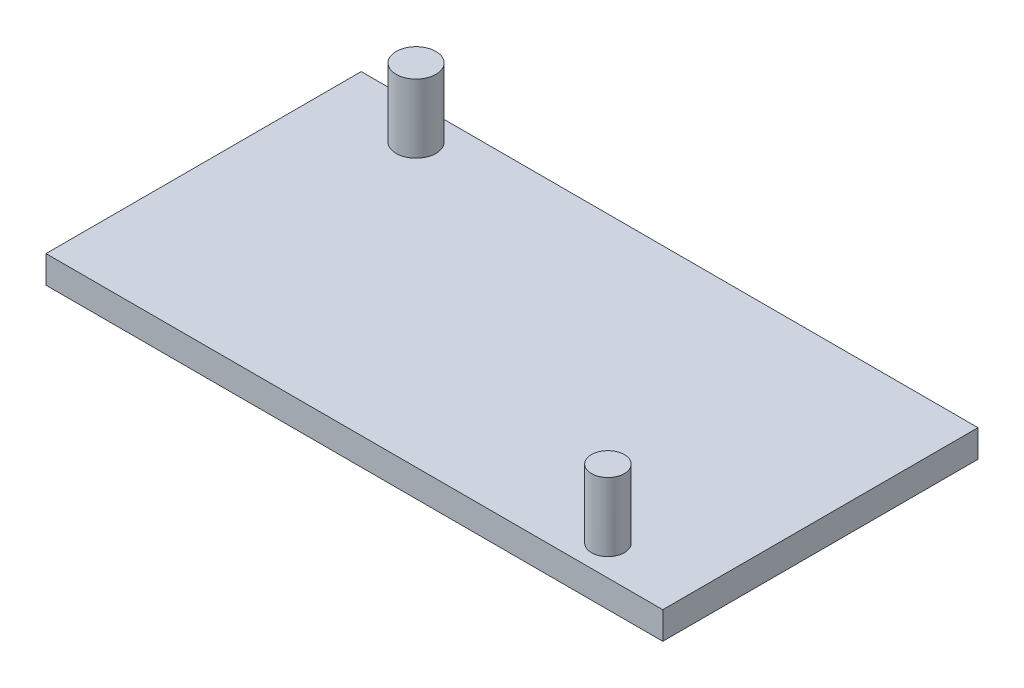
from build123d import *

# Parameters (mm, degrees)
SKETCH1_W           = 45
SKETCH1_H           = 23
BOSS_EXTRUDE1_DEPTH = 2
SKETCH2_R           = 1.1999976
BOSS_EXTRUDE2_DEPTH = 5
SKETCH3_R           = 1.45
BOSS_EXTRUDE3_DEPTH = 5


with BuildPart() as part:
    # Sketch1 → Boss-Extrude1 (new body)
    with BuildSketch(Plane(origin=(0, 0, 0), x_dir=(1, 0, 0), z_dir=(0, 1, 0))):
        with Locations((22.5, 11.5)):
            Rectangle(SKETCH1_W, SKETCH1_H)
    extrude(amount=-BOSS_EXTRUDE1_DEPTH)

    # Sketch2 → Boss-Extrude2 (add)
    with BuildSketch(Plane(origin=(0, 0, 0), x_dir=(1, 0, 0), z_dir=(0, 1, 0))):
        with Locations((38.8, 2.2)):
            Circle(SKETCH2_R)
    extrude(amount=BOSS_EXTRUDE2_DEPTH)

    # Sketch3 → Boss-Extrude3 (add)
    with BuildSketch(Plane(origin=(0, 0, 0), x_dir=(1, 0, 0), z_dir=(0, 1, 0))):
        with Locations((6.45, 20.5499922)):
            Circle(SKETCH3_R)
    extrude(amount=BOSS_EXTRUDE3_DEPTH)


solid = part.part
